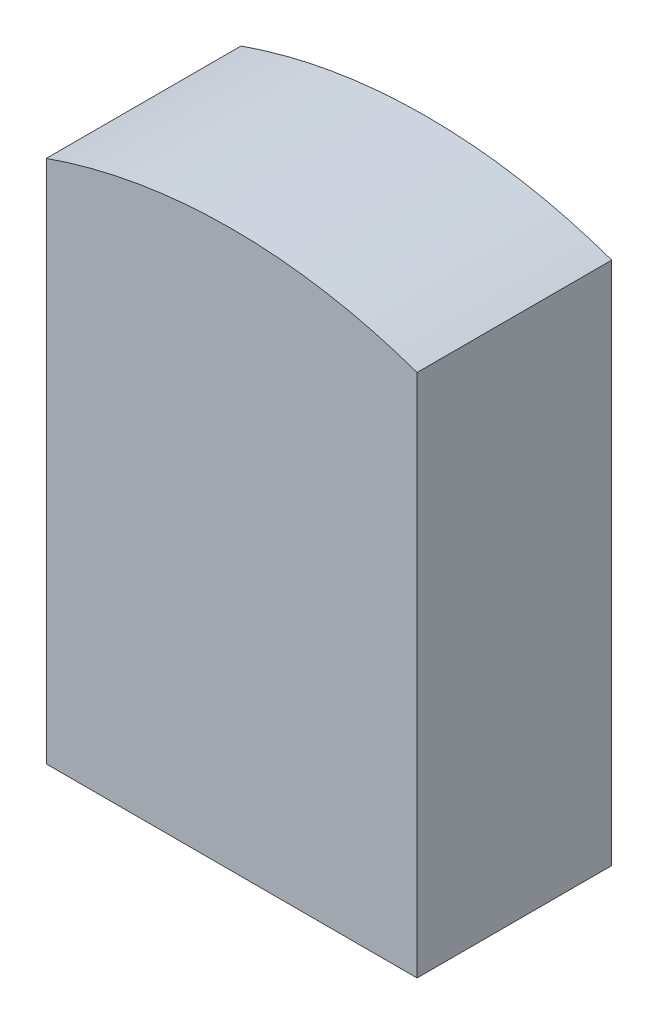
from build123d import *

# Parameters (mm, degrees)
BOSS_EXTRU_3_DEPTH = 70


with BuildPart() as part:
    # Esquisse2 → Boss.-Extru.3 (new body)
    with BuildSketch(Plane.XY):
        with BuildLine():
            Line((8.450324494, -169.122807018), (141.783657827, -169.122807018))
            Line((141.783657827, -169.122807018), (141.783657827, 19.439001299))
            ThreePointArc((141.783657827, 19.439001299), (75.116991161, 30.877192982), (8.450324494, 19.439001299))
            Line((8.450324494, 19.439001299), (8.450324494, -169.122807018))
        make_face()
    extrude(amount=BOSS_EXTRU_3_DEPTH)


solid = part.part
